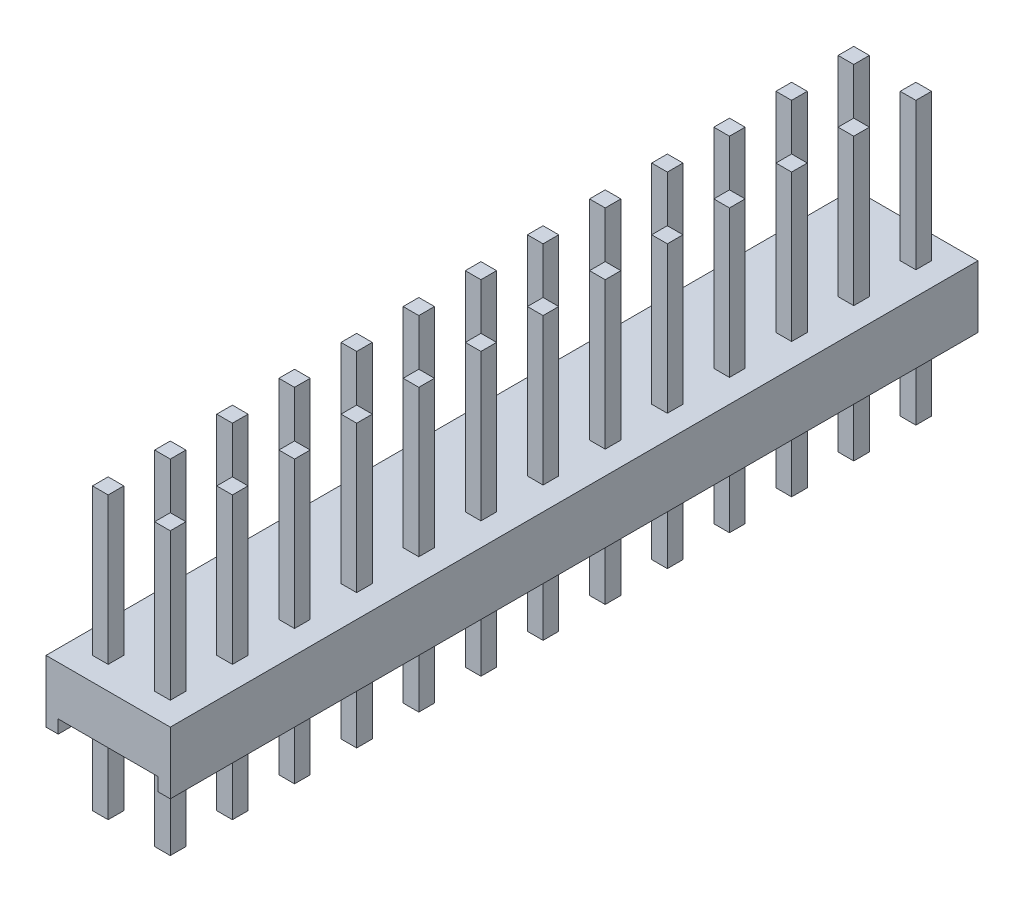
from build123d import *

# Parameters (mm, degrees)
EXTRUDE_1_DEPTH         = 2.54
EXTRUDE_START           = -5.5
SKETCH_2_W              = 0.64
SKETCH_2_H              = 0.64
EXTRUDE_2_DEPTH         = 11.5
PATTERN_LINEAR_27_COUNT = 13
PATTERN_LINEAR_27_PITCH = 2.54


with BuildPart() as part:
    # Эскиз1 → Бобышка-Вытянуть1 (new body)
    with BuildSketch(Plane.XY):
        Polygon((-2.54, 0), (-2.54, 2.54), (2.54, 2.54), (2.54, 0), (2.04, 0), (2.04, 0.54), (-2.04, 0.54), (-2.04, 0), align=None)
    extrude_1 = extrude(amount=EXTRUDE_1_DEPTH)

    # Эскиз2 → Бобышка-Вытянуть2 (add)
    with BuildSketch(Plane(origin=(0, 2.54, 0), x_dir=(1, 0, 0), z_dir=(0, 1, 0)).offset(EXTRUDE_START)):
        with Locations((-1.27, -1.27)):
            Rectangle(SKETCH_2_W, SKETCH_2_H)
        with Locations((1.27, -1.27)):
            Rectangle(SKETCH_2_W, SKETCH_2_H)
    extrude_2 = extrude(amount=EXTRUDE_2_DEPTH)

    # Линейный массив27: Бобышка-Вытянуть1, Бобышка-Вытянуть2 ×13
    with Locations(*[(0, 0, -i * PATTERN_LINEAR_27_PITCH) for i in range(1, PATTERN_LINEAR_27_COUNT)]):
        add(extrude_1)
        add(extrude_2)


solid = part.part
